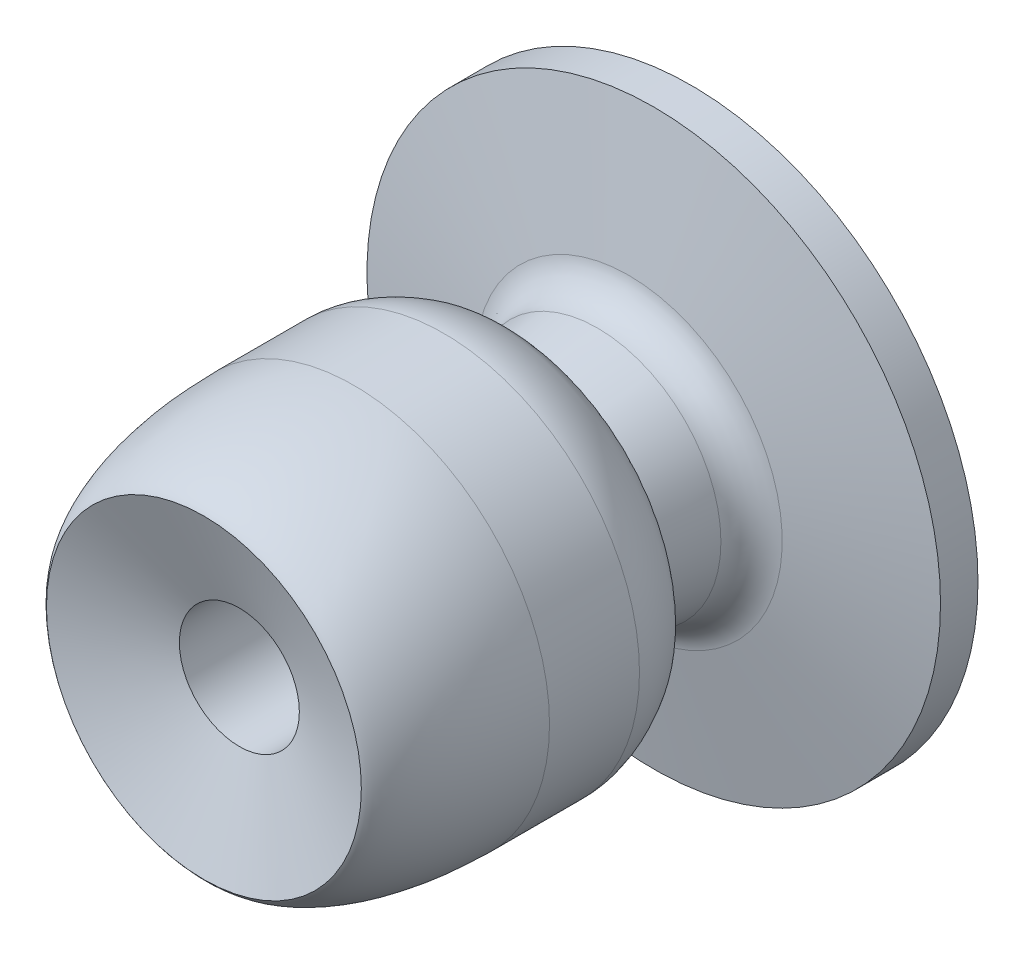
from build123d import *

# Parameters (mm, degrees)
SKETCH_1_R          = 38.25
EXTRUDE_1_DEPTH     = 5
FILLET_1_R          = 5
SKETCH_5_R          = 8
CUT_EXTRUDE_1_DEPTH = 66.0000001
SKETCH_6_W          = 20
SKETCH_6_H          = 20
EXTRUDE_2_DEPTH     = 10


with BuildPart() as part:
    # ｽｹｯﾁ1 → ﾎﾞｽ - 押し出し1 (new body)
    with BuildSketch(Plane.XY):
        Circle(SKETCH_1_R)
    extrude(amount=EXTRUDE_1_DEPTH)

    # ｽｹｯﾁ2 → 回転1 (revolve)
    with BuildSketch(Plane(origin=(0, 0, 0), x_dir=(0, 0, -1), z_dir=(1, 0, 0))):
        Polygon((-22, 0), (-22, 15), (-9, 17), (-5, 38.25), (-5, 0), align=None)
    revolve(axis=Axis((0, 0, 0), (0, 0, 1)))

    # ﾌｨﾚｯﾄ1
    fillet_1_edges = [part.edges().sort_by_distance(p)[0] for p in [
        (0, -17, 9),
    ]]
    fillet(fillet_1_edges, radius=FILLET_1_R)

    # ｽｹｯﾁ3 → 回転2 (revolve)
    with BuildSketch(Plane(origin=(0, 0, 0), x_dir=(0, 0, -1), z_dir=(1, 0, 0))):
        with BuildLine():
            Line((-45, 26.1), (-33, 26.1))
            add(Edge.make_bspline(
                [(-33, 26.1), (-30.010138273, 26.1), (-26.820768311, 24.254113599), (-25.622496591, 23.557974687), (-22.470712298, 20.950193944), (-22, 15)],
                knots=[0, 0, 0, 0, 0.463324442, 0.563324442, 1, 1, 1, 1], degree=3))
            Line((-22, 15), (-22, 0))
            Line((-22, 0), (-57.35662508, 0))
            Line((-57.35662508, 0), (-65, 21))
            add(Edge.make_bspline(
                [(-45, 26.1), (-57.846202283, 26.003969711), (-64.230299253, 22.294062624), (-65, 21)],
                knots=[0, 0, 0, 0, 1, 1, 1, 1], degree=3))
        make_face()
    revolve(axis=Axis((0, 0, 0), (0, 0, 1)))

    # ｽｹｯﾁ5 → ｶｯﾄ - 押し出し1 (cut, through all)
    with BuildSketch(Plane(origin=(0, 0, 0), x_dir=(-1, 0, 0), z_dir=(0, 0, -1))):
        Circle(SKETCH_5_R)
    extrude(amount=-CUT_EXTRUDE_1_DEPTH, mode=Mode.SUBTRACT)

    # ｽｹｯﾁ6 → ﾎﾞｽ - 押し出し2 (add)
    with BuildSketch(Plane(origin=(0, 0, 0), x_dir=(-1, 0, 0), z_dir=(0, 0, -1))):
        Rectangle(SKETCH_6_W, SKETCH_6_H)
    extrude(amount=EXTRUDE_2_DEPTH)


solid = part.part
